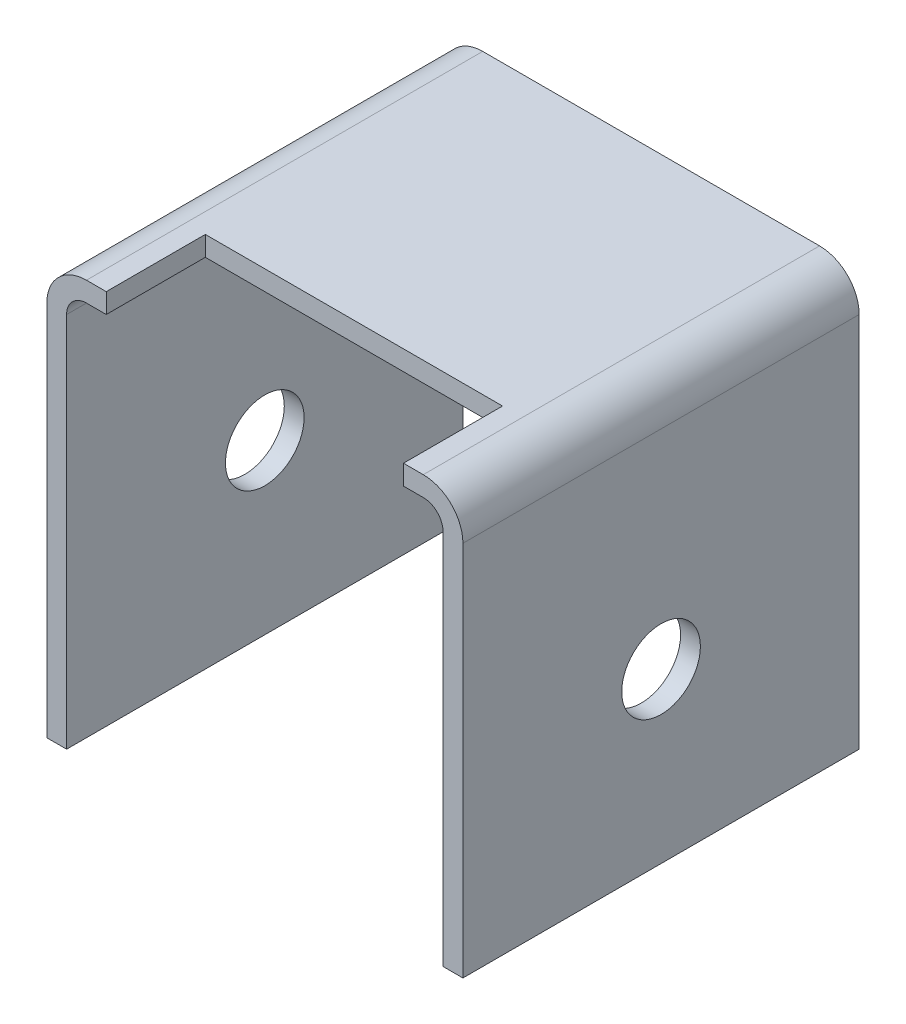
from build123d import *

# Parameters (mm, degrees)
EXTRUDE_THIN1_DEPTH     = 25.4
F_3_8_CLEARANCE_HOLE1_D = 10.0838
SKETCH4_W               = 38.1
SKETCH4_H               = 12.7
CUT_EXTRUDE1_DEPTH      = 3.54


with BuildPart() as part:
    # Sketch1 → Extrude-Thin1 (new body, symmetric)
    with BuildSketch(Plane.XY):
        with BuildLine():
            Line((-26.67, -53.34), (-26.67, -5.08))
            ThreePointArc((-26.67, -5.08), (-25.182102448, -1.487897552), (-21.59, 0))
            Line((-21.59, 0), (21.59, 0))
            ThreePointArc((21.59, 0), (25.182102448, -1.487897552), (26.67, -5.08))
            Line((26.67, -5.08), (26.67, -53.34))
            Line((26.67, -53.34), (24.13, -53.34))
            Line((24.13, -53.34), (24.13, -5.08))
            ThreePointArc((24.13, -5.08), (23.386051224, -3.283948776), (21.59, -2.54))
            Line((21.59, -2.54), (-21.59, -2.54))
            ThreePointArc((-21.59, -2.54), (-23.386051224, -3.283948776), (-24.13, -5.08))
            Line((-24.13, -5.08), (-24.13, -53.34))
            Line((-24.13, -53.34), (-26.67, -53.34))
        make_face()
    extrude(amount=EXTRUDE_THIN1_DEPTH, both=True)

    # 3/8 Clearance Hole1 (through all)
    with Locations(Plane(origin=(26.67, 0, 0), x_dir=(0, 0, -1), z_dir=(1, 0, 0))):
        with Locations((0, -31.75)):
            Hole(F_3_8_CLEARANCE_HOLE1_D / 2)

    # Sketch4 → Cut-Extrude1 (cut, through all)
    with BuildSketch(Plane.XZ.offset(2.54)):
        with Locations((0, 19.05)):
            Rectangle(SKETCH4_W, SKETCH4_H)
    extrude(amount=-CUT_EXTRUDE1_DEPTH, mode=Mode.SUBTRACT)


solid = part.part
